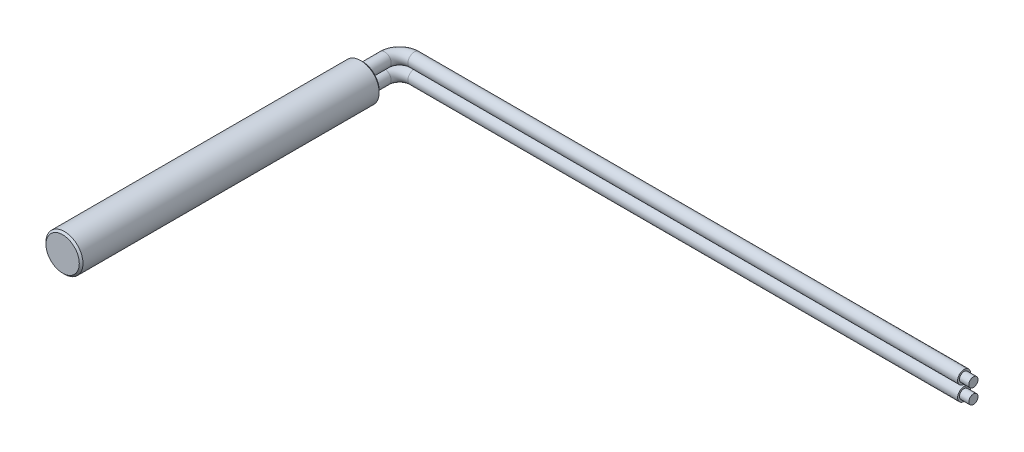
from build123d import *

# Parameters (mm, degrees)
SKETCH1_R           = 1
CASING_DEPTH        = 16.2
CASING_CHAMFER_SIZE = 0.1
SKETCH3_R           = 0.35
SKETCH4_R           = 0.25
EXPOSED_WIRE_DEPTH  = 0.5


with BuildPart() as part:
    # Sketch1 → Casing (new body)
    with BuildSketch(Plane.XY):
        Circle(SKETCH1_R)
    extrude(amount=CASING_DEPTH)

    # Casing Chamfer
    casing_chamfer_edges = [part.edges().sort_by_distance(p)[0] for p in [
        (-1, 0, 0),
        (-1, 0, 16.2),
    ]]
    chamfer(casing_chamfer_edges, length=CASING_CHAMFER_SIZE)

    # Wire 2: sweep along a path in Sketch2
    with BuildLine(Plane(origin=(0, 0, 0), x_dir=(1, 0, 0), z_dir=(0, 1, 0))) as wire_2_path:
        Line((0, 0), (0, 1.2))
        ThreePointArc((0, 1.2), (0.234314575, 1.765685425), (0.8, 2))
        Line((0.8, 2), (30.5, 2))
    # Sketch3 → Wire 2 (sweep)
    with BuildSketch(Plane(origin=(0, 0, 0), x_dir=(-1, 0, 0), z_dir=(0, 0, -1))):
        with Locations((0, -0.4)):
            Circle(SKETCH3_R)
        with Locations((0, 0.4)):
            Circle(SKETCH3_R)
    sweep(path=wire_2_path.line)

    # Sketch4 → Exposed Wire (add)
    with BuildSketch(Plane(origin=(30.5, 0, 0), x_dir=(0, 0, -1), z_dir=(1, 0, 0))):
        with Locations((2, 0.4)):
            Circle(SKETCH4_R)
        with Locations((2, -0.4)):
            Circle(SKETCH4_R)
    extrude(amount=EXPOSED_WIRE_DEPTH)


solid = part.part
